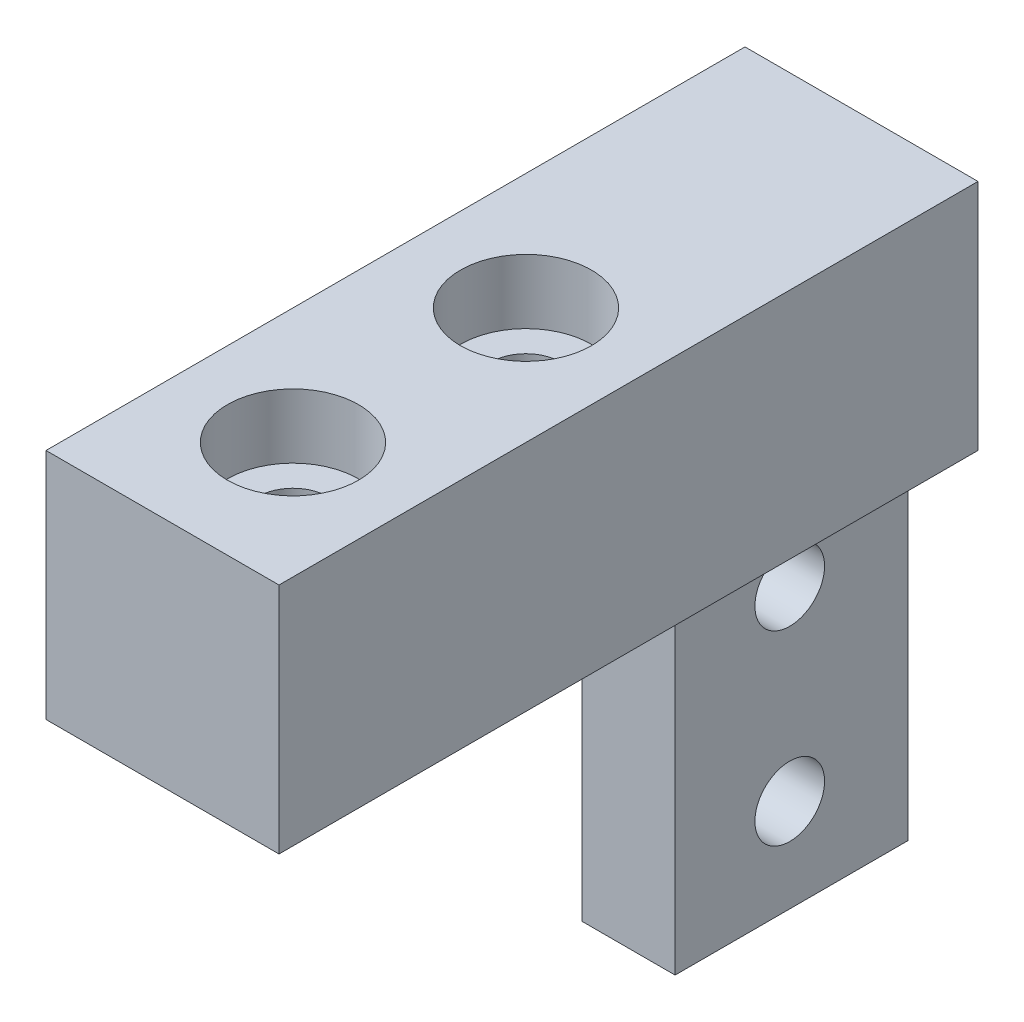
from build123d import *

# Parameters (mm, degrees)
SKETCH1_W                                      = 38.1
SKETCH1_H                                      = 12.7
BOSS_EXTRUDE1_DEPTH                            = 12.7
SKETCH2_W                                      = 12.7
SKETCH2_H                                      = 12.7
BOSS_EXTRUDE2_DEPTH                            = 20.32
SKETCH3_W                                      = 3.81
SKETCH3_H                                      = 20.32
CUT_EXTRUDE1_DEPTH                             = 12.7
F_6_CLEARANCE_HOLE1_D                          = 3.7973
F_6_CLEARANCE_HOLE1_DEPTH                      = 10.16
F_6_CLEARANCE_HOLE1_TIP                        = 1.140824014
CBORE_FOR_6_SOCKET_HEAD_CAP_SCREW1_D           = 3.7973
CBORE_FOR_6_SOCKET_HEAD_CAP_SCREW1_CBORE_D     = 7.14502
CBORE_FOR_6_SOCKET_HEAD_CAP_SCREW1_CBORE_DEPTH = 3.5052


with BuildPart() as part:
    # Sketch1 → Boss-Extrude1 (new body)
    with BuildSketch(Plane(origin=(0, 0, 0), x_dir=(0, 0, -1), z_dir=(1, 0, 0))):
        with Locations((19.05, -6.35)):
            Rectangle(SKETCH1_W, SKETCH1_H)
    extrude(amount=BOSS_EXTRUDE1_DEPTH)

    # Sketch2 → Boss-Extrude2 (add)
    with BuildSketch(Plane.XZ.offset(12.7)):
        with Locations((6.35, -31.75)):
            Rectangle(SKETCH2_W, SKETCH2_H)
    extrude(amount=BOSS_EXTRUDE2_DEPTH)

    # Sketch3 → Cut-Extrude1 (cut)
    with BuildSketch(Plane(origin=(0, 0, -38.1), x_dir=(-1, 0, 0), z_dir=(0, 0, -1))):
        with Locations((-10.795, -22.86)):
            Rectangle(SKETCH3_W, SKETCH3_H)
        with Locations((-1.905, -22.86)):
            Rectangle(SKETCH3_W, SKETCH3_H)
    extrude(amount=-CUT_EXTRUDE1_DEPTH, mode=Mode.SUBTRACT)

    # #6 Clearance Hole1
    with Locations(Plane(origin=(8.89, 0, 0), x_dir=(0, 0, -1), z_dir=(1, 0, 0))):
        with Locations((31.647977642, -17.78), (31.647977642, -27.94), (44.509550176, -23.706107059)):
            Hole(F_6_CLEARANCE_HOLE1_D / 2, depth=F_6_CLEARANCE_HOLE1_DEPTH)
            with Locations((0, 0, -(F_6_CLEARANCE_HOLE1_DEPTH + F_6_CLEARANCE_HOLE1_TIP / 2))):  # 118° drill point
                Cone(0, F_6_CLEARANCE_HOLE1_D / 2, F_6_CLEARANCE_HOLE1_TIP, mode=Mode.SUBTRACT)

    # CBORE for #6 Socket Head Cap Screw1 (through all)
    with Locations(Plane(origin=(0, 0, 0), x_dir=(1, 0, 0), z_dir=(0, 1, 0))):
        with Locations((6.35, 7.112), (6.35, 19.812)):
            CounterBoreHole(CBORE_FOR_6_SOCKET_HEAD_CAP_SCREW1_D / 2, CBORE_FOR_6_SOCKET_HEAD_CAP_SCREW1_CBORE_D / 2, CBORE_FOR_6_SOCKET_HEAD_CAP_SCREW1_CBORE_DEPTH)


solid = part.part
